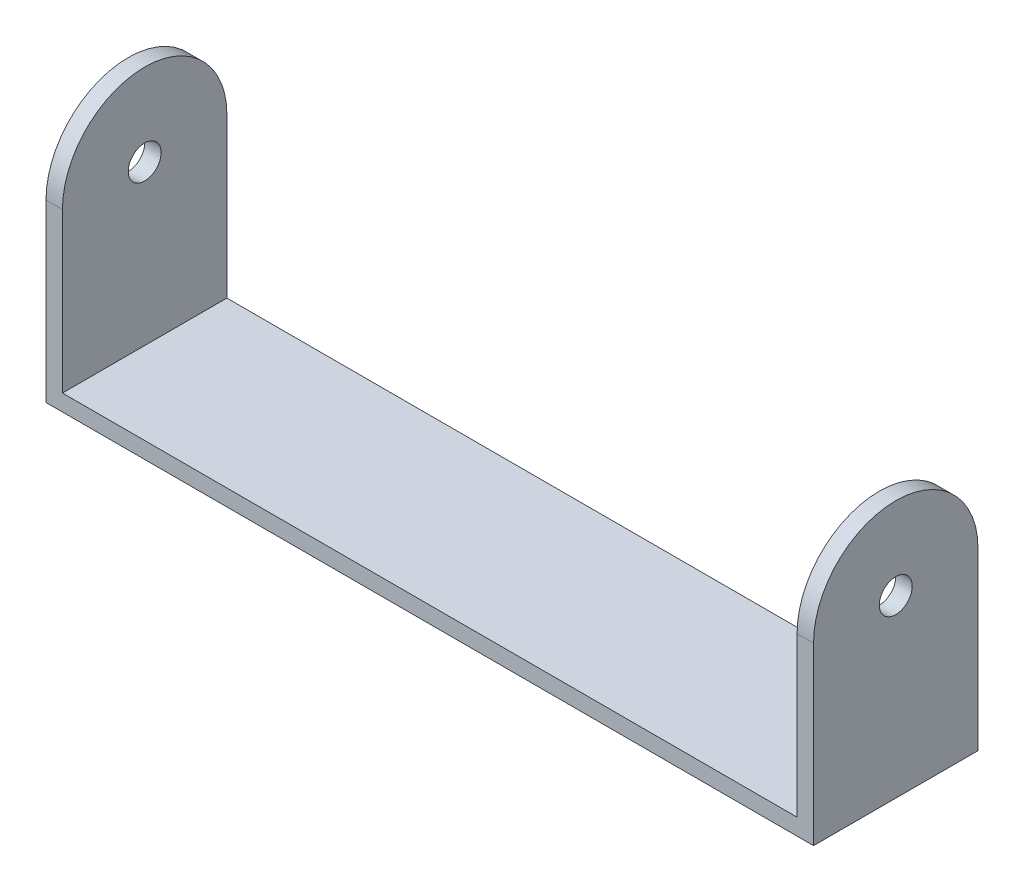
from build123d import *

# Parameters (mm, degrees)
SKETCH1_W           = 70
SKETCH1_H           = 15
BOSS_EXTRUDE1_DEPTH = 1.5
SKETCH2_W           = 1.5
SKETCH2_H           = 15
BOSS_EXTRUDE2_DEPTH = 22
SKETCH3_R           = 1.5
CUT_EXTRUDE1_DEPTH  = 71


with BuildPart() as part:
    # Sketch1 → Boss-Extrude1 (new body)
    with BuildSketch(Plane(origin=(0, 0, 0), x_dir=(1, 0, 0), z_dir=(0, 1, 0))):
        Rectangle(SKETCH1_W, SKETCH1_H)
    extrude(amount=BOSS_EXTRUDE1_DEPTH)

    # Sketch2 → Boss-Extrude2 (add)
    with BuildSketch(Plane(origin=(0, 1.5, 0), x_dir=(1, 0, 0), z_dir=(0, 1, 0))):
        with Locations((-34.25, 0)):
            Rectangle(SKETCH2_W, SKETCH2_H)
        with Locations((34.25, 0)):
            Rectangle(SKETCH2_W, SKETCH2_H)
    extrude(amount=BOSS_EXTRUDE2_DEPTH)

    # Sketch3 → Cut-Extrude1 (cut, through all)
    with BuildSketch(Plane.ZY.offset(35)):
        with BuildLine():
            Line((7.5, 23.5), (0, 23.5))
            ThreePointArc((0, 23.5), (5.303300859, 21.303300859), (7.5, 16))
            Line((7.5, 16), (7.5, 23.5))
        make_face()
        with BuildLine():
            Line((-7.5, 23.5), (-7.5, 16))
            ThreePointArc((-7.5, 16), (-5.303300859, 21.303300859), (0, 23.5))
            Line((0, 23.5), (-7.5, 23.5))
        make_face()
        with Locations((0, 16)):
            Circle(SKETCH3_R)
    extrude(amount=-CUT_EXTRUDE1_DEPTH, mode=Mode.SUBTRACT)


solid = part.part
